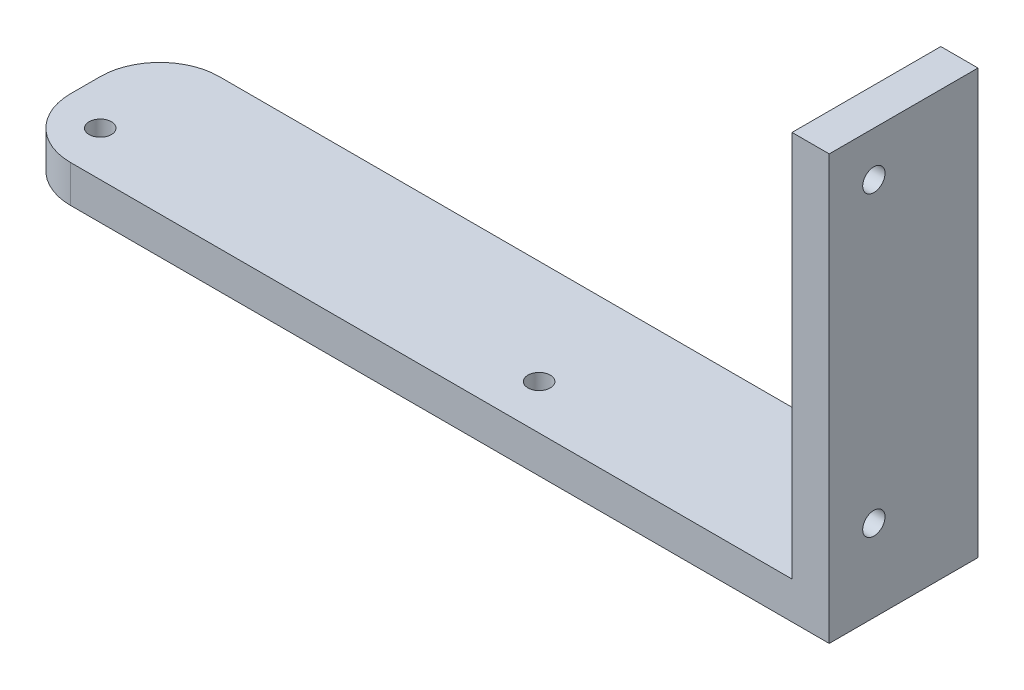
from build123d import *

# Parameters (mm, degrees)
SKETCH1_W           = 110
SKETCH1_H           = 20
BOSS_EXTRUDE1_DEPTH = 5
SKETCH2_W           = 5
SKETCH2_H           = 20
BOSS_EXTRUDE2_DEPTH = 52
SKETCH3_R           = 1.5
CUT_EXTRUDE1_DEPTH  = 6
FILLET1_R           = 8
SKETCH4_R           = 1.5
CUT_EXTRUDE2_DEPTH  = 6


with BuildPart() as part:
    # Sketch1 → Boss-Extrude1 (new body)
    with BuildSketch(Plane(origin=(0, 0, 0), x_dir=(1, 0, 0), z_dir=(0, 1, 0))):
        with Locations((55, 10)):
            Rectangle(SKETCH1_W, SKETCH1_H)
    extrude(amount=BOSS_EXTRUDE1_DEPTH)

    # Sketch2 → Boss-Extrude2 (add)
    with BuildSketch(Plane(origin=(0, 5, 0), x_dir=(1, 0, 0), z_dir=(0, 1, 0))):
        with Locations((107.5, 10)):
            Rectangle(SKETCH2_W, SKETCH2_H)
    extrude(amount=BOSS_EXTRUDE2_DEPTH)

    # Sketch3 → Cut-Extrude1 (cut, through all)
    with BuildSketch(Plane(origin=(0, 5, 0), x_dir=(1, 0, 0), z_dir=(0, 1, 0))):
        with Locations((6, 6)):
            Circle(SKETCH3_R)
        with Locations((65, 6)):
            Circle(SKETCH3_R)
    extrude(amount=-CUT_EXTRUDE1_DEPTH, mode=Mode.SUBTRACT)

    # Fillet1
    fillet1_edges = [part.edges().sort_by_distance(p)[0] for p in [
        (0, 2.5, 0),
        (0, 2.5, -20),
    ]]
    fillet(fillet1_edges, radius=FILLET1_R)

    # Sketch4 → Cut-Extrude2 (cut, through all)
    with BuildSketch(Plane.ZY.offset(-105)):
        with Locations((-6, 11)):
            Circle(SKETCH4_R)
        with Locations((-6, 51)):
            Circle(SKETCH4_R)
    extrude(amount=-CUT_EXTRUDE2_DEPTH, mode=Mode.SUBTRACT)


solid = part.part
